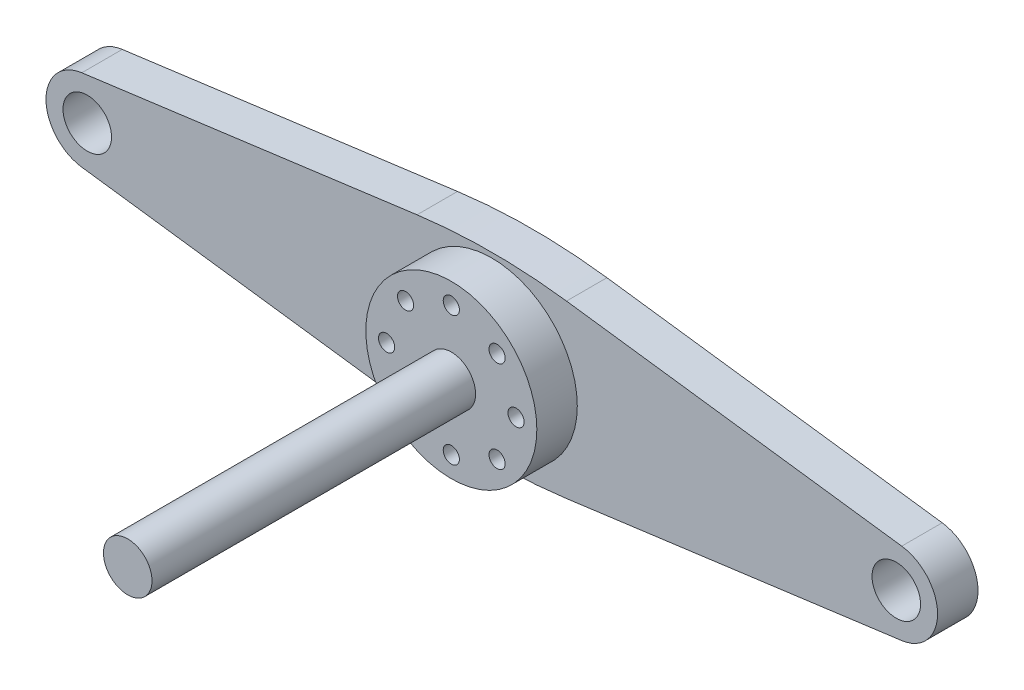
from build123d import *

# Parameters (mm, degrees)
SZKIC1_R                    = 3
SZKIC1_R_2                  = 1
DODANIE_WYCI_GNI_CIE1_DEPTH = 5
SZKIC1_3_R                  = 10.570763761
SZKIC1_3_R_2                = 1
SZKIC1_3_R_3                = 3
DODANIE_WYCI_GNI_CIE2_DEPTH = 10
SZKIC1_4_R                  = 3
DODANIE_WYCI_GNI_CIE3_DEPTH = 50


with BuildPart() as part:
    # Szkic1 → Dodanie-wyci_gni_cie1 (new body)
    with BuildSketch(Plane.XY):
        with BuildLine():
            Line((-9.235111676, 10.570763761), (-50.67287635, 5.055665151))
            ThreePointArc((-50.67287635, 5.055665151), (-55.100246338, 0), (-50.67287635, -5.055665151))
            Line((-50.67287635, -5.055665151), (-9.235111676, -10.570763761))
            ThreePointArc((-9.235111676, -10.570763761), (0, -11.182632843), (9.235111676, -10.570763761))
            Line((9.235111676, -10.570763761), (50.67287635, -5.055665151))
            ThreePointArc((50.67287635, -5.055665151), (55.100246338, 0), (50.67287635, 5.055665151))
            Line((50.67287635, 5.055665151), (9.235111676, 10.570763761))
            ThreePointArc((9.235111676, 10.570763761), (0, 11.182632843), (-9.235111676, 10.570763761))
        make_face()
        with Locations((-50, 0)):
            Circle(SZKIC1_R, mode=Mode.SUBTRACT)
        with Locations((50, 0)):
            Circle(SZKIC1_R, mode=Mode.SUBTRACT)
        with Locations((0, 8)):
            Circle(SZKIC1_R_2, mode=Mode.SUBTRACT)
        with Locations((0, -8)):
            Circle(SZKIC1_R_2, mode=Mode.SUBTRACT)
        with Locations((-5.656854249, -5.656854249)):
            Circle(SZKIC1_R_2, mode=Mode.SUBTRACT)
        with Locations((-8, 0)):
            Circle(SZKIC1_R_2, mode=Mode.SUBTRACT)
        with Locations((5.656854249, -5.656854249)):
            Circle(SZKIC1_R_2, mode=Mode.SUBTRACT)
        with Locations((8, 0)):
            Circle(SZKIC1_R_2, mode=Mode.SUBTRACT)
        with Locations((-5.656854249, 5.656854249)):
            Circle(SZKIC1_R_2, mode=Mode.SUBTRACT)
        with Locations((5.656854249, 5.656854249)):
            Circle(SZKIC1_R_2, mode=Mode.SUBTRACT)
    extrude(amount=DODANIE_WYCI_GNI_CIE1_DEPTH)

    # Szkic1_3 → Dodanie-wyci_gni_cie2 (add)
    with BuildSketch(Plane.XY):
        Circle(SZKIC1_3_R)
        with Locations((0, -8)):
            Circle(SZKIC1_3_R_2, mode=Mode.SUBTRACT)
        with Locations((-5.656854249, -5.656854249)):
            Circle(SZKIC1_3_R_2, mode=Mode.SUBTRACT)
        with Locations((-8, 0)):
            Circle(SZKIC1_3_R_2, mode=Mode.SUBTRACT)
        Circle(SZKIC1_3_R_3, mode=Mode.SUBTRACT)
        with Locations((5.656854249, -5.656854249)):
            Circle(SZKIC1_3_R_2, mode=Mode.SUBTRACT)
        with Locations((8, 0)):
            Circle(SZKIC1_3_R_2, mode=Mode.SUBTRACT)
        with Locations((-5.656854249, 5.656854249)):
            Circle(SZKIC1_3_R_2, mode=Mode.SUBTRACT)
        with Locations((5.656854249, 5.656854249)):
            Circle(SZKIC1_3_R_2, mode=Mode.SUBTRACT)
        with Locations((0, 8)):
            Circle(SZKIC1_3_R_2, mode=Mode.SUBTRACT)
    extrude(amount=DODANIE_WYCI_GNI_CIE2_DEPTH)

    # Szkic1_4 → Dodanie-wyci_gni_cie3 (add)
    with BuildSketch(Plane.XY):
        Circle(SZKIC1_4_R)
    extrude(amount=DODANIE_WYCI_GNI_CIE3_DEPTH)


solid = part.part
